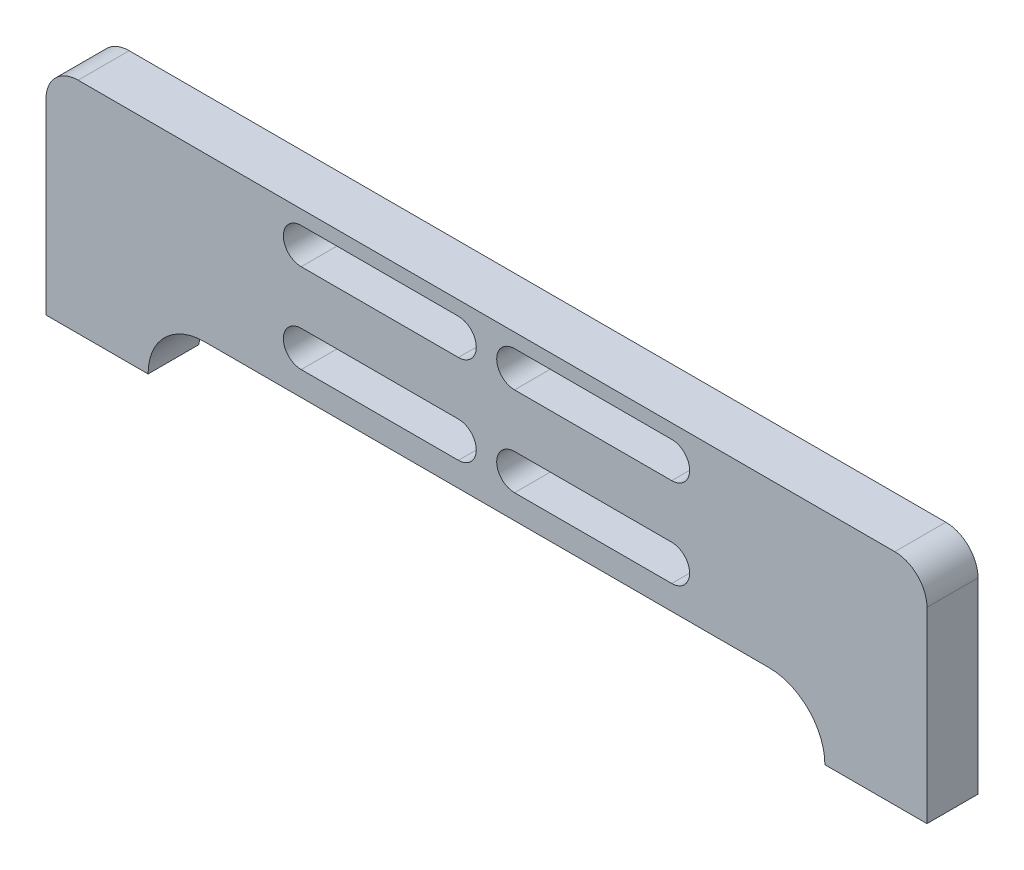
from build123d import *

# Parameters (mm, degrees)
SKETCH1_R               = 4.3
SKETCH1_W               = 12.5
SKETCH1_H               = 12.5
BOSS_EXTRUDE1_DEPTH     = 8
CUT_EXTRUDE1_DEPTH      = 8
SKETCH1_2_R             = 4.3
SKETCH1_2_W             = 12.5
SKETCH1_2_H             = 12.5
BOSS_EXTRUDE2_DEPTH     = 10
CUT_EXTRUDE2_DEPTH      = 92.3119085
CUT_EXTRUDE2_DEPTH_BACK = 92.3119085
SKETCH3_W               = 12.5
SKETCH3_H               = 12.5
BOSS_EXTRUDE3_DEPTH     = 2
BOSS_EXTRUDE5_START     = -2
SKETCH4_R               = 4.3
BOSS_EXTRUDE5_DEPTH     = 2
BOSS_EXTRUDE6_DEPTH     = 10
BOSS_EXTRUDE7_DEPTH     = 10
BOSS_EXTRUDE8_DEPTH     = 10


with BuildPart() as part:
    # Sketch1 → Boss-Extrude1 (new body)
    with BuildSketch(Plane.XY):
        with BuildLine():
            Line((-85.345346062, -25.7), (87.254653938, -25.7))
            Line((87.254653938, -25.7), (87.254653938, 0))
            ThreePointArc((87.254653938, 0), (85.409426659, 4.454772721), (80.954653938, 6.3))
            Line((80.954653938, 6.3), (-79.045346062, 6.3))
            ThreePointArc((-79.045346062, 6.3), (-83.500118784, 4.454772721), (-85.345346062, 0))
            Line((-85.345346062, 0), (-85.345346062, -25.7))
        make_face()
        with Locations((-79.045346062, 0)):
            Circle(SKETCH1_R, mode=Mode.SUBTRACT)
        with Locations((80.954653938, 0)):
            Circle(SKETCH1_R, mode=Mode.SUBTRACT)
        with Locations((-77.095346062, -17.45)):
            Rectangle(SKETCH1_W, SKETCH1_H, mode=Mode.SUBTRACT)
        with Locations((79.004653938, -17.45)):
            Rectangle(SKETCH1_W, SKETCH1_H, mode=Mode.SUBTRACT)
    extrude(amount=BOSS_EXTRUDE1_DEPTH)

    # Sketch2 → Cut-Extrude1 (cut)
    with BuildSketch(Plane.XY.offset(8)):
        with BuildLine():
            Line((-35.345346062, 3.5), (37.254653938, 3.5))
            ThreePointArc((37.254653938, 3.5), (40.754653938, 0), (37.254653938, -3.5))
            Line((37.254653938, -3.5), (-35.345346062, -3.5))
            ThreePointArc((-35.345346062, -3.5), (-38.845346062, 0), (-35.345346062, 3.5))
        make_face()
        with BuildLine():
            Line((-35.345346062, -13.95), (37.254653938, -13.95))
            ThreePointArc((37.254653938, -13.95), (40.754653938, -17.45), (37.254653938, -20.95))
            Line((37.254653938, -20.95), (34.643207431, -20.95))
            Line((34.643207431, -20.95), (-35.345346062, -20.95))
            ThreePointArc((-35.345346062, -20.95), (-38.845346062, -17.45), (-35.345346062, -13.95))
        make_face()
    extrude(amount=-CUT_EXTRUDE1_DEPTH, mode=Mode.SUBTRACT)

    # Sketch1_2 → Boss-Extrude2 (add)
    with BuildSketch(Plane.XY):
        with BuildLine():
            Line((-85.345346062, -25.7), (87.254653938, -25.7))
            Line((87.254653938, -25.7), (87.254653938, 0))
            ThreePointArc((87.254653938, 0), (85.409426659, 4.454772721), (80.954653938, 6.3))
            Line((80.954653938, 6.3), (-79.045346062, 6.3))
            ThreePointArc((-79.045346062, 6.3), (-83.500118784, 4.454772721), (-85.345346062, 0))
            Line((-85.345346062, 0), (-85.345346062, -25.7))
        make_face()
        with Locations((-79.045346062, 0)):
            Circle(SKETCH1_2_R, mode=Mode.SUBTRACT)
        with Locations((80.954653938, 0)):
            Circle(SKETCH1_2_R, mode=Mode.SUBTRACT)
        with Locations((-77.095346062, -17.45)):
            Rectangle(SKETCH1_2_W, SKETCH1_2_H, mode=Mode.SUBTRACT)
        with Locations((79.004653938, -17.45)):
            Rectangle(SKETCH1_2_W, SKETCH1_2_H, mode=Mode.SUBTRACT)
    extrude(amount=BOSS_EXTRUDE2_DEPTH)

    # Sketch2_2 → Cut-Extrude2 (cut, two sides: drawn at the far end of the back side and taken through both)
    with BuildSketch(Plane.XY.offset(8).offset(-CUT_EXTRUDE2_DEPTH_BACK)):
        with BuildLine():
            Line((-35.345346062, 3.5), (37.254653938, 3.5))
            ThreePointArc((37.254653938, 3.5), (40.754653938, 0), (37.254653938, -3.5))
            Line((37.254653938, -3.5), (-35.345346062, -3.5))
            ThreePointArc((-35.345346062, -3.5), (-38.845346062, 0), (-35.345346062, 3.5))
        make_face()
        with BuildLine():
            Line((-35.345346062, -13.95), (37.254653938, -13.95))
            ThreePointArc((37.254653938, -13.95), (40.754653938, -17.45), (37.254653938, -20.95))
            Line((37.254653938, -20.95), (34.643207431, -20.95))
            Line((34.643207431, -20.95), (-35.345346062, -20.95))
            ThreePointArc((-35.345346062, -20.95), (-38.845346062, -17.45), (-35.345346062, -13.95))
        make_face()
    extrude(amount=CUT_EXTRUDE2_DEPTH + CUT_EXTRUDE2_DEPTH_BACK, mode=Mode.SUBTRACT)

    # Sketch3 → Boss-Extrude3 (add)
    with BuildSketch(Plane.XY.offset(10)):
        with Locations((-77.095346062, -17.45)):
            Rectangle(SKETCH3_W, SKETCH3_H)
        with Locations((79.004653938, -17.45)):
            Rectangle(SKETCH3_W, SKETCH3_H)
    extrude(amount=-BOSS_EXTRUDE3_DEPTH)

    # Sketch4 → Boss-Extrude5 (add)
    with BuildSketch(Plane.XY.offset(10).offset(BOSS_EXTRUDE5_START)):
        with Locations((-79.045346062, 0)):
            Circle(SKETCH4_R)
        with Locations((80.954653938, 0)):
            Circle(SKETCH4_R)
    extrude(amount=BOSS_EXTRUDE5_DEPTH)

    # Sketch5 → Boss-Extrude6 (add)
    with BuildSketch(Plane.XY.offset(10)):
        with BuildLine():
            Line((-4.545346062, 3.5), (6.454653938, 3.5))
            ThreePointArc((6.454653938, 3.5), (2.954653938, 0), (6.454653938, -3.5))
            Line((6.454653938, -3.5), (-4.545346062, -3.5))
            ThreePointArc((-4.545346062, -3.5), (-1.045346062, 0), (-4.545346062, 3.5))
        make_face()
    extrude(amount=-BOSS_EXTRUDE6_DEPTH)

    # Sketch6 → Boss-Extrude7 (add)
    with BuildSketch(Plane.XY.offset(10)):
        with BuildLine():
            Line((-4.545346062, -13.95), (6.454653938, -13.95))
            ThreePointArc((6.454653938, -13.95), (2.954653938, -17.45), (6.454653938, -20.95))
            Line((6.454653938, -20.95), (-4.545346062, -20.95))
            ThreePointArc((-4.545346062, -20.95), (-1.045346062, -17.45), (-4.545346062, -13.95))
        make_face()
    extrude(amount=-BOSS_EXTRUDE7_DEPTH)

    # Sketch7 → Boss-Extrude8 (add)
    with BuildSketch(Plane.XY.offset(10)):
        with BuildLine():
            Line((-85.345346062, -25.7), (-85.345346062, -36.7))
            Line((-85.345346062, -36.7), (-65.345346062, -36.7))
            ThreePointArc((-65.345346062, -36.7), (-62.123520655, -28.921825407), (-54.345346062, -25.7))
            Line((-54.345346062, -25.7), (-85.345346062, -25.7))
        make_face()
        with BuildLine():
            Line((87.254653938, -25.7), (87.254653938, -36.7))
            Line((87.254653938, -36.7), (67.254653938, -36.7))
            ThreePointArc((67.254653938, -36.7), (64.032828531, -28.921825407), (56.254653938, -25.7))
            Line((56.254653938, -25.7), (87.254653938, -25.7))
        make_face()
    extrude(amount=-BOSS_EXTRUDE8_DEPTH)


solid = part.part
